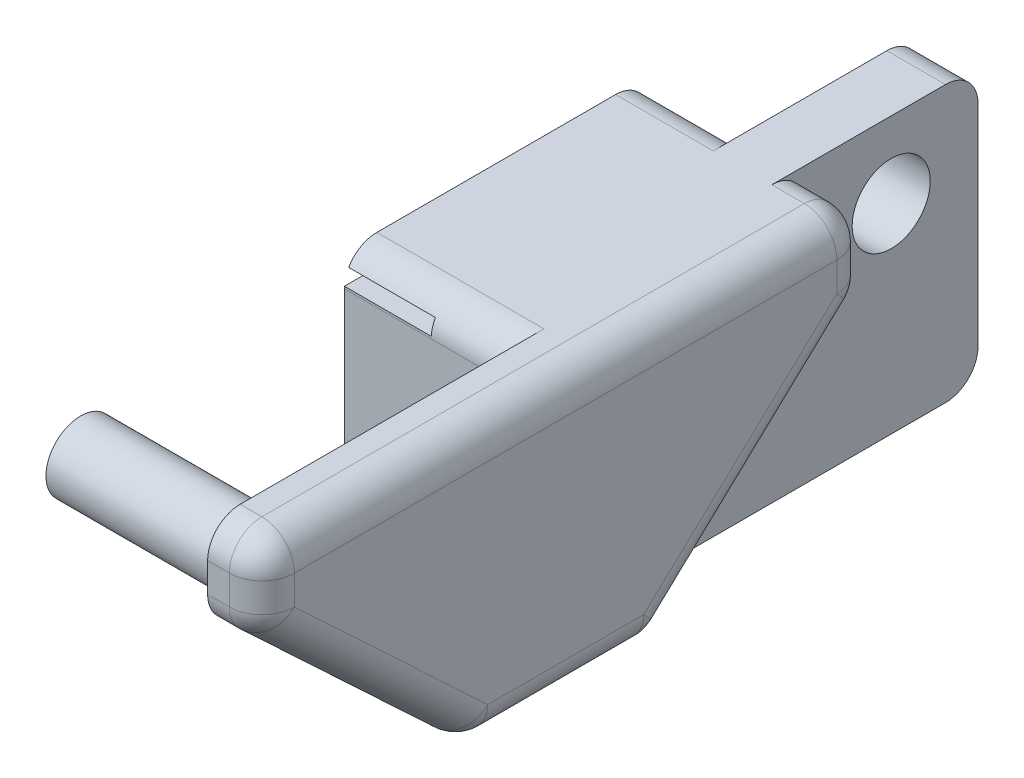
from build123d import *

# Parameters (mm, degrees)
BOSS_EXTRUDE1_DEPTH = 12.7
CUT_EXTRUDE2_DEPTH  = 4.5
CUT_EXTRUDE3_DEPTH  = 11.2
BOSS_EXTRUDE2_START = -7.7
SKETCH2_5_R         = 1.6
BOSS_EXTRUDE2_DEPTH = 9.1
SKETCH2_6_R         = 1.8
CUT_EXTRUDE4_DEPTH  = 11.2
SKETCH2_7_R         = 1.6
BOSS_EXTRUDE3_DEPTH = 1.4
SKETCH2_8_W         = 36
SKETCH2_8_H         = 0.65
CUT_EXTRUDE5_DEPTH  = 4
CUT_EXTRUDE6_DEPTH  = 3
SKETCH4_W           = 1.5
SKETCH4_H           = 22
CUT_EXTRUDE7_DEPTH  = 3
SKETCH6_W           = 2.1
SKETCH6_H           = 4.185
BOSS_EXTRUDE4_DEPTH = 1
CUT_EXTRUDE9_START  = -10.2
CUT_EXTRUDE9_DEPTH  = 4.5
FILLET3_R           = 1.5
FILLET2_R           = 0.25


with BuildPart() as part:
    # Sketch1 → Boss-Extrude1 (new body)
    with BuildSketch(Plane(origin=(0, 0, 0), x_dir=(1, 0, 0), z_dir=(0, 1, 0))):
        Polygon((-28.77817965, 9.54419618), (-24.27817965, 9.54419618), (-24.27817965, 17.54419618), (-21.57817965, 17.54419618), (-21.57817965, 9.54419618), (-18.57817965, 9.54419618), (-18.57817965, -18.45580382), (-21.07817965, -18.45580382), (-21.07817965, -4.45580382), (-28.77817965, -4.45580382), align=None)
    extrude(amount=BOSS_EXTRUDE1_DEPTH)

    # Sketch2 → Cut-Extrude2 (cut)
    with BuildSketch(Plane.ZY.offset(28.77817965)):
        Polygon((-9.54419618, 3.548072024), (-9.54419618, 0), (-3.657330191, 0), align=None)
    extrude(amount=-CUT_EXTRUDE2_DEPTH, mode=Mode.SUBTRACT)

    # Sketch2_4 → Cut-Extrude3 (cut, through all)
    with BuildSketch(Plane.ZY.offset(28.77817965)):
        Polygon((12.124702683, 0), (18.45580382, 0), (18.45580382, 9.2), align=None)
    extrude(amount=-CUT_EXTRUDE3_DEPTH, mode=Mode.SUBTRACT)

    # Sketch2_5 → Boss-Extrude2 (add)
    with BuildSketch(Plane.ZY.offset(28.77817965).offset(BOSS_EXTRUDE2_START)):
        with Locations((15.20580382, 9.2)):
            Circle(SKETCH2_5_R)
    extrude(amount=BOSS_EXTRUDE2_DEPTH)

    # Sketch2_6 → Cut-Extrude4 (cut, through all)
    with BuildSketch(Plane.ZY.offset(28.77817965)):
        with Locations((-13.54419618, 9.2)):
            Circle(SKETCH2_6_R)
    extrude(amount=-CUT_EXTRUDE4_DEPTH, mode=Mode.SUBTRACT)

    # Sketch2_7 → Boss-Extrude3 (add)
    with BuildSketch(Plane.ZY.offset(28.77817965)):
        with Locations((-6.29419618, 9.2)):
            Circle(SKETCH2_7_R)
    extrude(amount=BOSS_EXTRUDE3_DEPTH)

    # Sketch2_8 → Cut-Extrude5 (cut)
    with BuildSketch(Plane.ZY.offset(28.77817965)):
        with Locations((0.45580382, 11.625)):
            Rectangle(SKETCH2_8_W, SKETCH2_8_H)
    extrude(amount=-CUT_EXTRUDE5_DEPTH, mode=Mode.SUBTRACT)

    # Sketch3 → Cut-Extrude6 (cut)
    with BuildSketch(Plane(origin=(-18.57817965, 0, 0), x_dir=(0, 0, -1), z_dir=(1, 0, 0))):
        Polygon((9.54419618, 0), (9.54419618, 9.2), (-0.27080382, 0), align=None)
        Polygon((-12.124702683, 0), (-18.45580382, 9.2), (-18.45580382, 0), align=None)
        Polygon((-8.64080382, 0), (-18.45580382, 9.2), (-12.124702683, 0), align=None)
    extrude(amount=-CUT_EXTRUDE6_DEPTH, mode=Mode.SUBTRACT)

    # Sketch4 → Cut-Extrude7 (cut)
    with BuildSketch(Plane.XZ):
        with Locations((-22.92817965, -6.54419618)):
            Rectangle(SKETCH4_W, SKETCH4_H)
    extrude(amount=-CUT_EXTRUDE7_DEPTH, mode=Mode.SUBTRACT)

    # Sketch6 → Boss-Extrude4 (add)
    with BuildSketch(Plane(origin=(0, 0, 0), x_dir=(-1, 0, 0), z_dir=(0, -1, 0))):
        with Locations((22.62817965, -2.36330382)):
            Rectangle(SKETCH6_W, SKETCH6_H)
    extrude(amount=-BOSS_EXTRUDE4_DEPTH)

    # Sketch3_3 → Cut-Extrude9 (cut)
    with BuildSketch(Plane(origin=(-18.57817965, 0, 0), x_dir=(0, 0, -1), z_dir=(1, 0, 0)).offset(CUT_EXTRUDE9_START)):
        Polygon((9.54419618, 0), (9.54419618, 9.2), (-0.27080382, 0), align=None)
    extrude(amount=CUT_EXTRUDE9_DEPTH, mode=Mode.SUBTRACT)

    # Fillet3
    fillet3_edges = [part.edges().sort_by_distance(p)[0] for p in [
        (-18.57817965, 0, 4.45580382),
        (-18.57817965, 10.95, 18.45580382),
        (-18.57817965, 4.6, 13.54830382),
        (-18.57817965, 4.6, -4.63669618),
        (-18.57817965, 10.95, -9.54419618),
        (-18.57817965, 12.7, 4.45580382),
        (-24.92817965, 12.7, 4.45580382),
        (-19.82817965, 0, 8.64080382),
        (-19.82817965, 9.2, 18.45580382),
        (-19.82817965, 12.7, 18.45580382),
        (-26.52817965, 0, 0.27080382),
        (-20.07817965, 0, 0.27080382),
        (-20.07817965, 9.2, -9.54419618),
        (-20.07817965, 12.7, -9.54419618),
        (-26.52817965, 9.2, -9.54419618),
        (-26.52817965, 12.7, -9.54419618),
        (-21.87817965, 0, -17.54419618),
        (-23.97817965, 0, -17.54419618),
        (-22.92817965, 12.7, -17.54419618),
    ]]
    fillet(fillet3_edges, radius=FILLET3_R)

    # Fillet2
    fillet2_edges = [part.edges().sort_by_distance(p)[0] for p in [
        (-22.17817965, 3, -6.54419618),
        (-22.17817965, 2, 4.45580382),
        (-22.92817965, 3, -17.54419618),
        (-22.17817965, 2.25, -17.54419618),
        (-23.67817965, 3, -6.54419618),
        (-23.67817965, 2.25, -17.54419618),
        (-22.92817965, 3, 4.45580382),
        (-23.67817965, 2, 4.45580382),
        (-23.67817965, 0, -7.88669618),
        (-22.17817965, 0, -7.88669618),
        (-22.17817965, 0.439339828, -17.104856352),
        (-23.67817965, 0.439339828, -17.104856352),
    ]]
    fillet(fillet2_edges, radius=FILLET2_R)


solid = part.part
